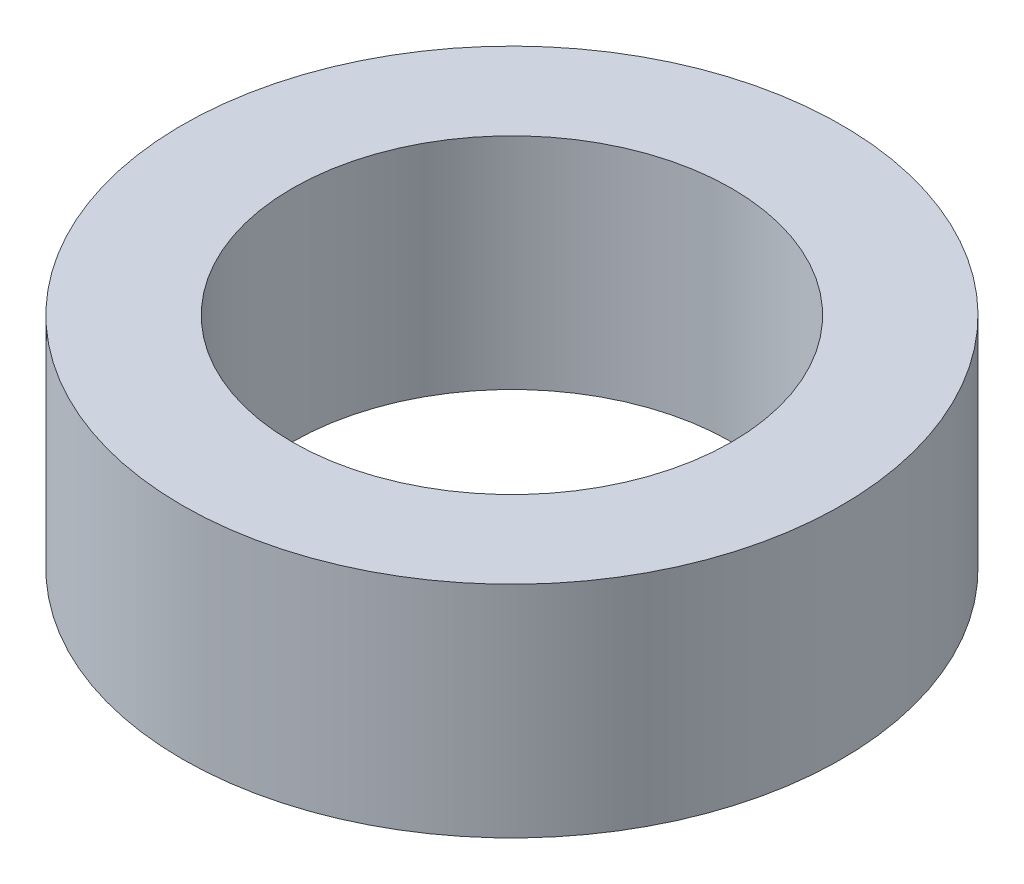
from build123d import *

# Parameters (mm, degrees)
SKETCH1_R           = 19.05
SKETCH1_R_2         = 12.7
BOSS_EXTRUDE1_DEPTH = 12.7


with BuildPart() as part:
    # Sketch1 → Boss-Extrude1 (new body)
    with BuildSketch(Plane(origin=(0, 0, 0), x_dir=(1, 0, 0), z_dir=(0, 1, 0))):
        Circle(SKETCH1_R)
        Circle(SKETCH1_R_2, mode=Mode.SUBTRACT)
    extrude(amount=BOSS_EXTRUDE1_DEPTH)


solid = part.part
